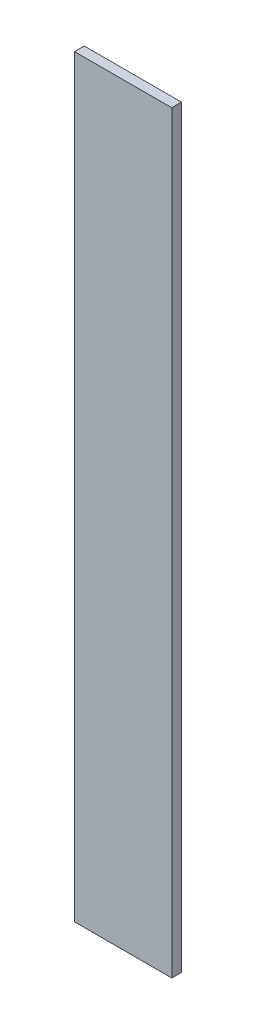
from build123d import *

# Parameters (mm, degrees)
ESBO_O1_W                = 200
ESBO_O1_H                = 20
RESSALTO_EXTRUS_O1_DEPTH = 1550


with BuildPart() as part:
    # Esboço1 → Ressalto-extrusão1 (new body)
    with BuildSketch(Plane(origin=(0, 0, 0), x_dir=(1, 0, 0), z_dir=(0, 1, 0))):
        with Locations((-29.608938547, 57.458100559)):
            Rectangle(ESBO_O1_W, ESBO_O1_H)
    extrude(amount=RESSALTO_EXTRUS_O1_DEPTH)


solid = part.part
